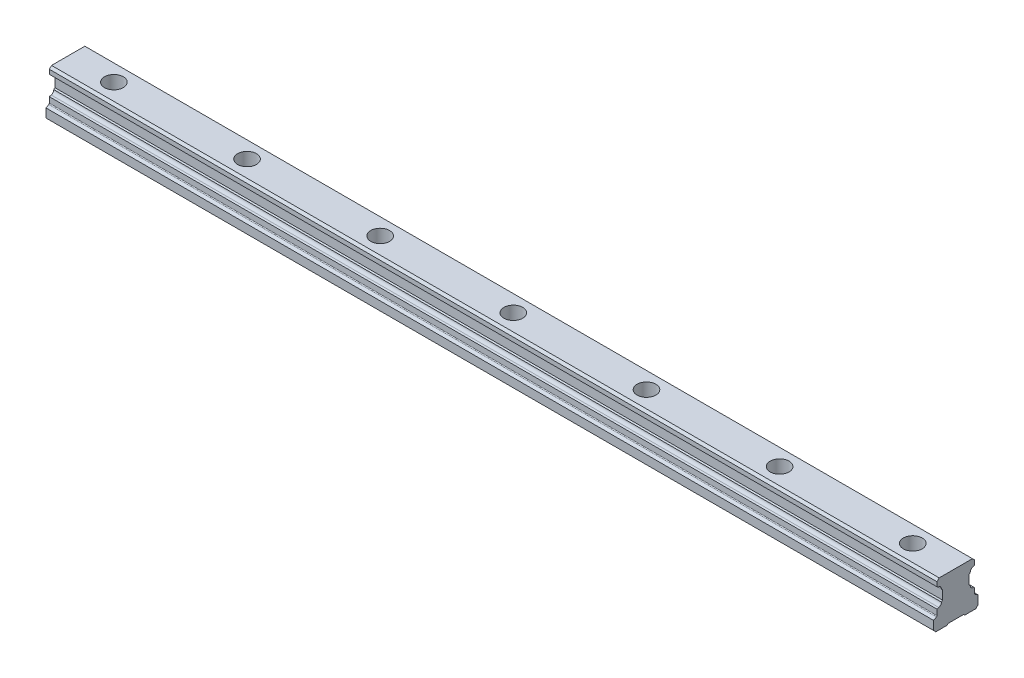
from build123d import *

# Parameters (mm, degrees)
BOSS_EXTRUDE5_DEPTH = 400
SKETCH8_R           = 4.25
CUT_EXTRUDE1_DEPTH  = 9
SKETCH9_R           = 3
CUT_EXTRUDE2_DEPTH  = 12.3
LPATTERN1_COUNT     = 20
LPATTERN1_PITCH     = 60


with BuildPart() as part:
    # Sketch7 → Boss-Extrude5 (new body)
    with BuildSketch(Plane(origin=(58.5, 0, 0), x_dir=(0, 0, -1), z_dir=(1, 0, 0))):
        with BuildLine():
            Line((-7.709038211, 8.883084864), (-8.5, 8.601077183))
            Line((-8.5, 8.601077183), (-8.5, 6.104700538))
            ThreePointArc((-8.5, 6.104700538), (-8.566987298, 5.854700538), (-8.75, 5.671687836))
            Line((-8.75, 5.671687836), (-10, 4.95))
            Line((-10, 4.95), (-10, 1))
            Line((-10, 1), (-9, 0))
            Line((-9, 0), (-4, 0))
            Line((-4, 0), (-3.5, 0.5))
            Line((-3.5, 0.5), (3.5, 0.5))
            Line((3.5, 0.5), (4, 0))
            Line((4, 0), (9, 0))
            Line((9, 0), (10, 1))
            Line((10, 1), (10, 4.95))
            Line((10, 4.95), (8.75, 5.671687836))
            ThreePointArc((8.75, 5.671687836), (8.566987298, 5.854700538), (8.5, 6.104700538))
            Line((8.5, 6.104700538), (8.5, 8.46691323))
            Line((8.5, 8.46691323), (8.084678947, 8.882234283))
            ThreePointArc((8.084678947, 8.882234283), (6.941822875, 9.249266637), (6.503340774, 10.366659226))
            Line((6.503340774, 10.366659226), (6, 10.87))
            Line((6, 10.87), (6, 14.93))
            Line((6, 14.93), (6.503340774, 15.433340774))
            ThreePointArc((6.503340774, 15.433340774), (6.813545517, 16.412959034), (7.709038211, 16.916915136))
            Line((7.709038211, 16.916915136), (8.5, 17.198922817))
            Line((8.5, 17.198922817), (8.5, 19.3))
            Line((8.5, 19.3), (7.5, 20.3))
            Line((7.5, 20.3), (-7.5, 20.3))
            Line((-7.5, 20.3), (-8.5, 19.3))
            Line((-8.5, 19.3), (-8.5, 17.33308677))
            Line((-8.5, 17.33308677), (-8.084678947, 16.917765717))
            ThreePointArc((-8.084678947, 16.917765717), (-6.941822875, 16.550733363), (-6.503340774, 15.433340774))
            Line((-6.503340774, 15.433340774), (-6, 14.93))
            Line((-6, 14.93), (-6, 10.87))
            Line((-6, 10.87), (-6.503340774, 10.366659226))
            ThreePointArc((-6.503340774, 10.366659226), (-6.813545517, 9.387040966), (-7.709038211, 8.883084864))
        make_face()
    extrude(amount=BOSS_EXTRUDE5_DEPTH)

    # Sketch8 → Cut-Extrude1 (cut)
    with BuildSketch(Plane(origin=(0, 20.3, 0), x_dir=(1, 0, 0), z_dir=(0, 1, 0))):
        with Locations((79.1, 0)):
            Circle(SKETCH8_R)
    cut_extrude1 = extrude(amount=-CUT_EXTRUDE1_DEPTH, mode=Mode.SUBTRACT)

    # Sketch9 → Cut-Extrude2 (cut, through all)
    with BuildSketch(Plane(origin=(0, 11.3, 0), x_dir=(1, 0, 0), z_dir=(0, 1, 0))):
        with Locations((79.1, 0)):
            Circle(SKETCH9_R)
    cut_extrude2 = extrude(amount=-CUT_EXTRUDE2_DEPTH, mode=Mode.SUBTRACT)

    # LPattern1: Cut-Extrude1, Cut-Extrude2 ×20
    with Locations(*[(i * LPATTERN1_PITCH, 0, 0) for i in range(1, LPATTERN1_COUNT)]):
        add(cut_extrude1, mode=Mode.SUBTRACT)
        add(cut_extrude2, mode=Mode.SUBTRACT)


solid = part.part
